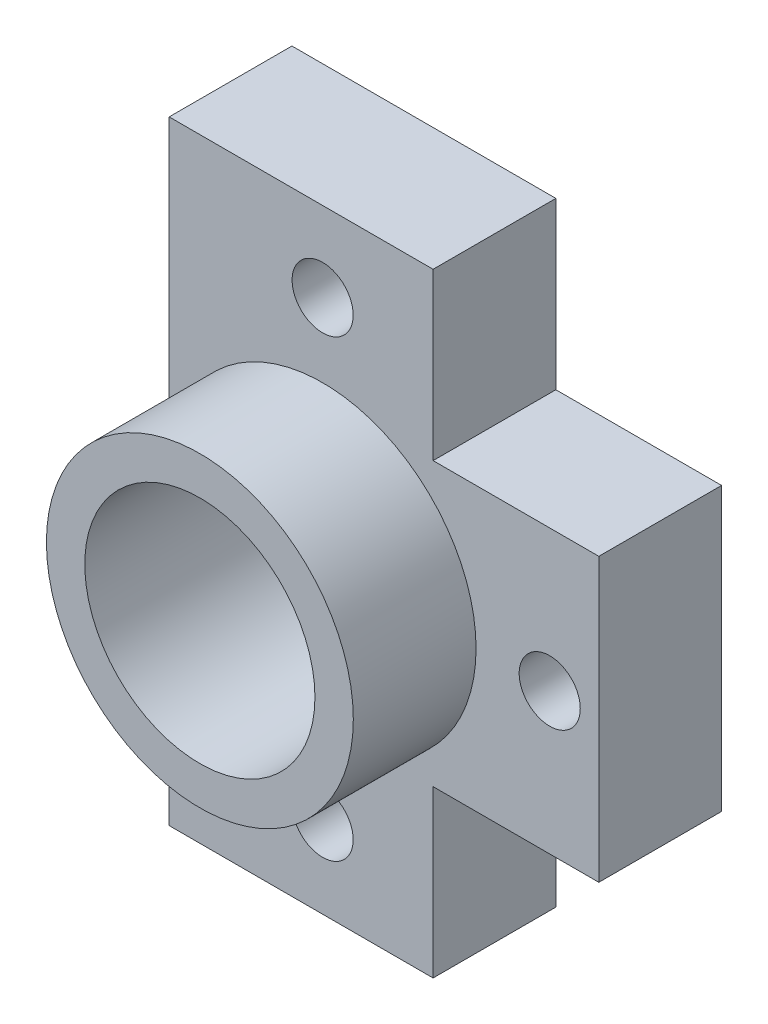
from build123d import *

# Parameters (mm, degrees)
SKETCH1_W                        = 17.78
SKETCH1_H                        = 25.4
EXTRUDE1_DEPTH                   = 10.16
F_3_8_0_375_DIAMETER_HOLE1_D     = 9.525
F_3_8_0_375_DIAMETER_HOLE1_DEPTH = 12.7
F_3_8_0_375_DIAMETER_HOLE1_TIP   = 2.861598698
SKETCH11_OUTSIDE_W               = 26.306
SKETCH11_OUTSIDE_H               = 33.926
SKETCH11_OUTSIDE_R               = 6.35
EXTRUDE3_DEPTH                   = 5.08
F_39_0_0995_DIAMETER_HOLE1_D     = 2.5273
SKETCH14_W                       = 6.858
SKETCH14_H                       = 6.858
EXTRUDE4_DEPTH                   = 6.08


with BuildPart() as part:
    # Sketch1 → Extrude1 (new body)
    with BuildSketch(Plane.XY):
        Rectangle(SKETCH1_W, SKETCH1_H)
    extrude(amount=EXTRUDE1_DEPTH)

    # 3/8 (0.375) Diameter Hole1
    with Locations(Plane(origin=(-2.54, 0, 10.16), x_dir=(1, 0, 0), z_dir=(0, 0, 1))):
        with Locations((0, 0)):
            Hole(F_3_8_0_375_DIAMETER_HOLE1_D / 2, depth=F_3_8_0_375_DIAMETER_HOLE1_DEPTH)
            with Locations((0, 0, -(F_3_8_0_375_DIAMETER_HOLE1_DEPTH + F_3_8_0_375_DIAMETER_HOLE1_TIP / 2))):  # 118° drill point
                Cone(0, F_3_8_0_375_DIAMETER_HOLE1_D / 2, F_3_8_0_375_DIAMETER_HOLE1_TIP, mode=Mode.SUBTRACT)

    # Sketch11 outside → Extrude3 (cut)
    with BuildSketch(Plane.XY.offset(10.16)):
        Rectangle(SKETCH11_OUTSIDE_W, SKETCH11_OUTSIDE_H)
        with Locations((-2.54, 0)):
            Circle(SKETCH11_OUTSIDE_R, mode=Mode.SUBTRACT)
    extrude(amount=-EXTRUDE3_DEPTH, mode=Mode.SUBTRACT)

    # #39 (0.0995) Diameter Hole1 (through all)
    with Locations(Plane(origin=(6.858, 0, 10.16), x_dir=(1, 0, 0), z_dir=(0, 0, 1))):
        with Locations((0, 0), (-9.398, -9.398), (-9.398, 9.398)):
            Hole(F_39_0_0995_DIAMETER_HOLE1_D / 2)

    # Sketch14 → Extrude4 (cut, through all)
    with BuildSketch(Plane.XY.offset(5.08)):
        with Locations((5.461, 9.271)):
            Rectangle(SKETCH14_W, SKETCH14_H)
        with Locations((5.461, -9.271)):
            Rectangle(SKETCH14_W, SKETCH14_H)
    extrude(amount=-EXTRUDE4_DEPTH, mode=Mode.SUBTRACT)


solid = part.part
